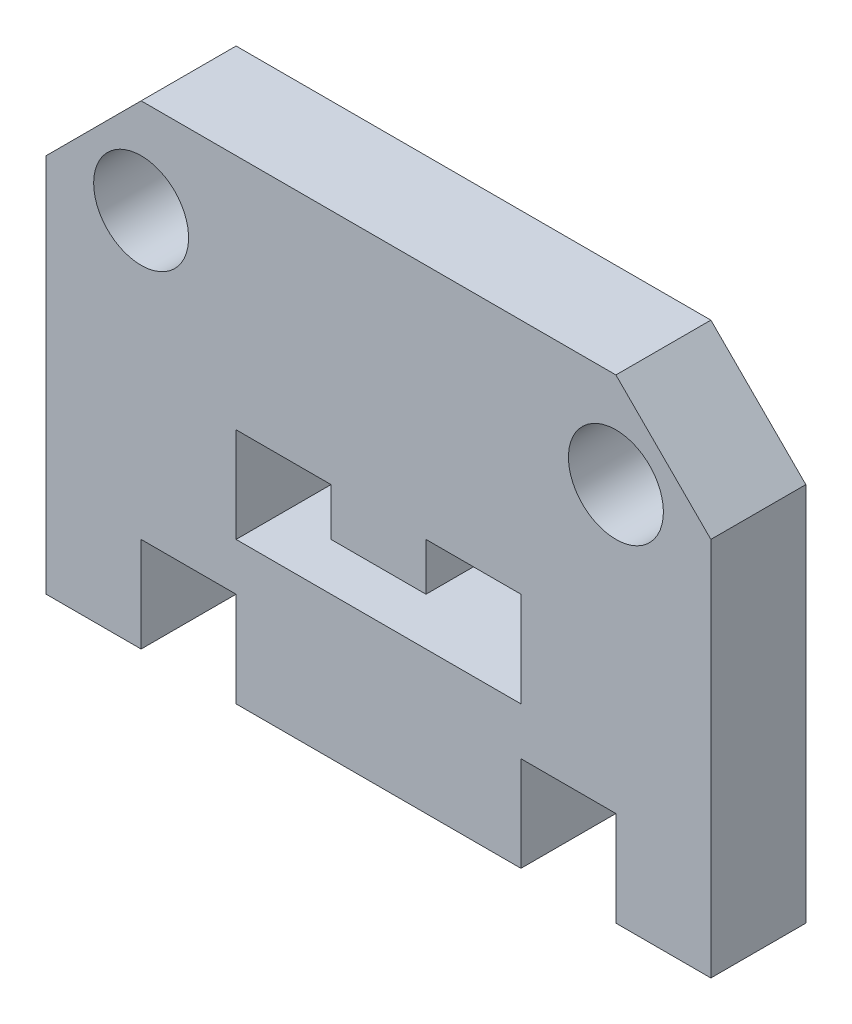
from build123d import *

# Parameters (mm, degrees)
SKETCH1_R           = 5
BOSS_EXTRUDE1_DEPTH = 10


with BuildPart() as part:
    # Sketch1 → Boss-Extrude1 (new body)
    with BuildSketch(Plane.XY):
        Polygon((-15, 0), (15, 0), (15, 10), (25, 10), (25, 0), (35, 0), (35, 40), (25, 50), (-25, 50), (-35, 40), (-35, 0), (-25, 0), (-25, 10), (-15, 10), align=None)
        with Locations((25, 40)):
            Circle(SKETCH1_R, mode=Mode.SUBTRACT)
        with Locations((-25, 40)):
            Circle(SKETCH1_R, mode=Mode.SUBTRACT)
        Polygon((-5, 20), (5, 20), (5, 25), (15, 25), (15, 15), (-15, 15), (-15, 25), (-5, 25), align=None, mode=Mode.SUBTRACT)
    extrude(amount=BOSS_EXTRUDE1_DEPTH)


solid = part.part
